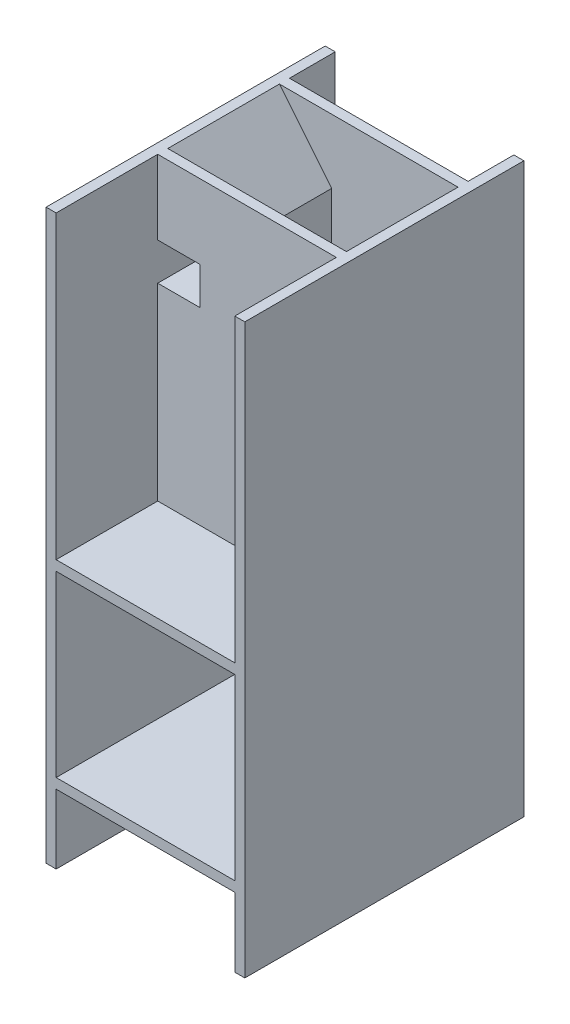
from build123d import *

# Parameters (mm, degrees)
SKETCH1_W            = 75.75
SKETCH1_H            = 67
BOSS_EXTRUDE4_DEPTH  = 150
SKETCH12_W           = 320
SKETCH12_H           = 18
BOSS_EXTRUDE6_DEPTH  = 115
BOSS_EXTRUDE8_DEPTH  = 200
BOSS_EXTRUDE9_DEPTH  = 200
SKETCH26_W           = 18
SKETCH26_H           = 1018
BOSS_EXTRUDE30_DEPTH = 200
SKETCH27_W           = 18
SKETCH27_H           = 1018
BOSS_EXTRUDE31_DEPTH = 200
SKETCH28_W           = 320
SKETCH28_H           = 18
BOSS_EXTRUDE32_DEPTH = 200
SKETCH29_W           = 320
SKETCH29_H           = 18
BOSS_EXTRUDE33_DEPTH = 200
SKETCH32_W           = 320
SKETCH32_H           = 538
BOSS_EXTRUDE35_DEPTH = 18
SKETCH34_W           = 75.75
SKETCH34_H           = 67
CUT_EXTRUDE1_DEPTH   = 18
SKETCH35_W           = 75.75
SKETCH35_H           = 67
CUT_EXTRUDE2_DEPTH   = 18
SKETCH46_W           = 93.75
SKETCH46_H           = 82
CUT_EXTRUDE14_DEPTH  = 85
SKETCH47_W           = 93.75
SKETCH47_H           = 82
CUT_EXTRUDE15_DEPTH  = 85
SKETCH48_W           = 132.5
SKETCH48_H           = 85
BOSS_EXTRUDE44_DEPTH = 18
SKETCH51_W           = 132.5
SKETCH51_H           = 18
BOSS_EXTRUDE46_DEPTH = 100


with BuildPart() as part:
    # Sketch1 → Boss-Extrude4 (new body, symmetric)
    with BuildSketch(Plane.XY):
        Polygon((66.25, 263), (66.25, 160), (160, 66.25), (160, -66.25), (66.25, -160), (66.25, -178), (160, -178), (160, -498), (-160, -498), (-160, -178), (-66.25, -178), (-66.25, -160), (-160, -66.25), (-160, 66.25), (-66.25, 160), (-66.25, 263), (-160, 263), (-160, 378), (-178, 378), (-178, -640), (-160, -640), (-160, -516), (160, -516), (160, -640), (178, -640), (178, 378), (160, 378), (160, 263), align=None)
        Polygon((-84.25, -160), (-160, -160), (-160, -84.25), align=None, mode=Mode.SUBTRACT)
        Polygon((160, -84.25), (160, -160), (84.25, -160), align=None, mode=Mode.SUBTRACT)
        Polygon((84.25, 160), (160, 160), (160, 84.25), align=None, mode=Mode.SUBTRACT)
        with Locations((122.125, 211.5)):
            Rectangle(SKETCH1_W, SKETCH1_H, mode=Mode.SUBTRACT)
        with Locations((-122.125, 211.5)):
            Rectangle(SKETCH1_W, SKETCH1_H, mode=Mode.SUBTRACT)
        Polygon((-84.25, 160), (-160, 84.25), (-160, 160), align=None, mode=Mode.SUBTRACT)
    extrude(amount=BOSS_EXTRUDE4_DEPTH, both=True)

    # Sketch12 → Boss-Extrude6 (add)
    with BuildSketch(Plane(origin=(0, 263, 0), x_dir=(-1, 0, 0), z_dir=(0, -1, 0))):
        with Locations((0, 59)):
            Rectangle(SKETCH12_W, SKETCH12_H)
    extrude(amount=-BOSS_EXTRUDE6_DEPTH)

    # Sketch13 → Boss-Extrude8 (add)
    with BuildSketch(Plane.XY.offset(150)):
        Polygon((-160, 378), (-66.25, 263), (-84.25, 263), (-160, 355.92), align=None)
    extrude(amount=-BOSS_EXTRUDE8_DEPTH)

    # Sketch15 → Boss-Extrude9 (add)
    with BuildSketch(Plane.XY.offset(150)):
        Polygon((160, 378), (66.25, 263), (84.25, 263), (160, 355.92), align=None)
    extrude(amount=-BOSS_EXTRUDE9_DEPTH)

    # Sketch26 → Boss-Extrude30 (add)
    with BuildSketch(Plane.XY.offset(150)):
        with Locations((-169, -131)):
            Rectangle(SKETCH26_W, SKETCH26_H)
    extrude(amount=BOSS_EXTRUDE30_DEPTH)

    # Sketch27 → Boss-Extrude31 (add)
    with BuildSketch(Plane.XY.offset(150)):
        with Locations((169, -131)):
            Rectangle(SKETCH27_W, SKETCH27_H)
    extrude(amount=BOSS_EXTRUDE31_DEPTH)

    # Sketch28 → Boss-Extrude32 (add)
    with BuildSketch(Plane.XY.offset(150)):
        with Locations((0, -169)):
            Rectangle(SKETCH28_W, SKETCH28_H)
    extrude(amount=BOSS_EXTRUDE32_DEPTH)

    # Sketch29 → Boss-Extrude33 (add)
    with BuildSketch(Plane.XY.offset(150)):
        with Locations((0, -507)):
            Rectangle(SKETCH29_W, SKETCH29_H)
    extrude(amount=BOSS_EXTRUDE33_DEPTH)

    # Sketch32 → Boss-Extrude35 (add)
    with BuildSketch(Plane.XY.offset(150)):
        with Locations((0, 109)):
            Rectangle(SKETCH32_W, SKETCH32_H)
    extrude(amount=BOSS_EXTRUDE35_DEPTH)

    # Sketch34 → Cut-Extrude1 (cut)
    with BuildSketch(Plane(origin=(0, 0, 150), x_dir=(-1, 0, 0), z_dir=(0, 0, -1))):
        with Locations((-122.125, 211.5)):
            Rectangle(SKETCH34_W, SKETCH34_H)
    extrude(amount=-CUT_EXTRUDE1_DEPTH, mode=Mode.SUBTRACT)

    # Sketch35 → Cut-Extrude2 (cut)
    with BuildSketch(Plane(origin=(0, 0, 150), x_dir=(-1, 0, 0), z_dir=(0, 0, -1))):
        with Locations((122.125, 211.5)):
            Rectangle(SKETCH35_W, SKETCH35_H)
    extrude(amount=-CUT_EXTRUDE2_DEPTH, mode=Mode.SUBTRACT)

    # Sketch46 → Cut-Extrude14 (cut)
    with BuildSketch(Plane(origin=(0, 263, 0), x_dir=(1, 0, 0), z_dir=(0, 1, 0))):
        with Locations((113.125, 109)):
            Rectangle(SKETCH46_W, SKETCH46_H)
    extrude(amount=-CUT_EXTRUDE14_DEPTH, mode=Mode.SUBTRACT)

    # Sketch47 → Cut-Extrude15 (cut)
    with BuildSketch(Plane(origin=(0, 263, 0), x_dir=(1, 0, 0), z_dir=(0, 1, 0))):
        with Locations((-113.125, 109)):
            Rectangle(SKETCH47_W, SKETCH47_H)
    extrude(amount=-CUT_EXTRUDE15_DEPTH, mode=Mode.SUBTRACT)

    # Sketch48 → Boss-Extrude44 (add)
    with BuildSketch(Plane(origin=(0, 0, -68), x_dir=(-1, 0, 0), z_dir=(0, 0, -1))):
        with Locations((0, 220.5)):
            Rectangle(SKETCH48_W, SKETCH48_H)
    extrude(amount=-BOSS_EXTRUDE44_DEPTH)

    # Sketch51 → Boss-Extrude46 (add)
    with BuildSketch(Plane(origin=(0, 0, -150), x_dir=(-1, 0, 0), z_dir=(0, 0, -1))):
        with Locations((0, 169)):
            Rectangle(SKETCH51_W, SKETCH51_H)
    extrude(amount=-BOSS_EXTRUDE46_DEPTH)


solid = part.part
